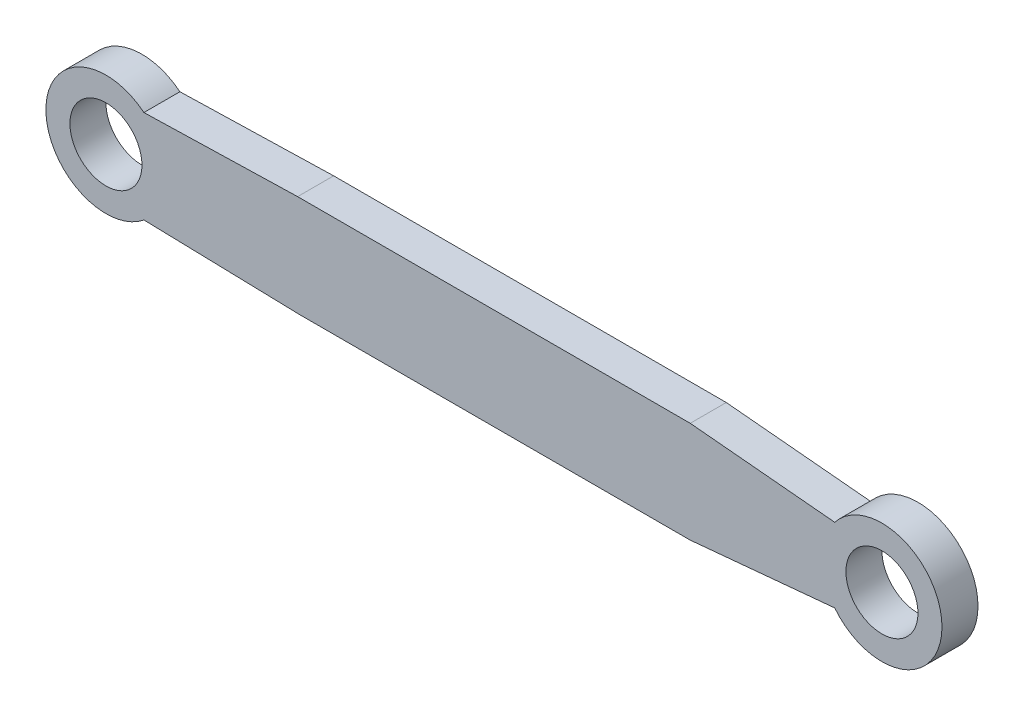
from build123d import *

# Parameters (mm, degrees)
SKETCH1_R           = 30
BOSS_EXTRUDE1_DEPTH = 30


with BuildPart() as part:
    # Sketch1 → Boss-Extrude1 (new body)
    with BuildSketch(Plane.XY):
        with BuildLine():
            Line((-163.480061578, 42.114452454), (-291.506249588, 38.739141102))
            ThreePointArc((-291.506249588, 38.739141102), (-373.11762328, 0), (-291.506249588, -38.739141102))
            Line((-291.506249588, -38.739141102), (-161.55881164, -42.158253128))
            Line((-161.55881164, -42.158253128), (163.480061578, -42.158253128))
            Line((163.480061578, -42.158253128), (283.79954089, -30.888321372))
            ThreePointArc((283.79954089, -30.888321372), (373.11762328, 0), (283.79954089, 30.888321372))
            Line((283.79954089, 30.888321372), (163.480061578, 42.114452454))
            Line((163.480061578, 42.114452454), (-163.480061578, 42.114452454))
        make_face()
        with Locations((-323.11762328, 0)):
            Circle(SKETCH1_R, mode=Mode.SUBTRACT)
        with Locations((323.11762328, 0)):
            Circle(SKETCH1_R, mode=Mode.SUBTRACT)
    extrude(amount=BOSS_EXTRUDE1_DEPTH)


solid = part.part
